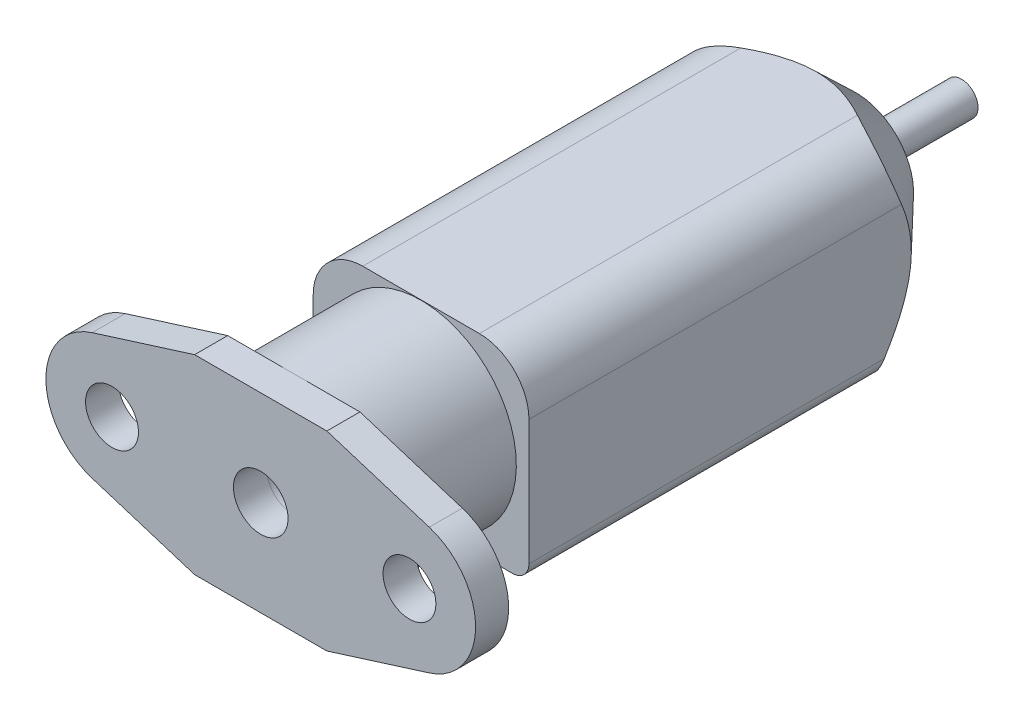
from build123d import *

# Parameters (mm, degrees)
CROQUIS1_R               = 1.598160281
CROQUIS1_R_2             = 1.600993429
CROQUIS1_R_3             = 1.650918845
SALIENTE_EXTRUIR7_DEPTH  = 2
CROQUIS2_R               = 5.764999893
CROQUIS2_R_2             = 1.651186543
SALIENTE_EXTRUIR8_DEPTH  = 7.7
SALIENTE_EXTRUIR9_DEPTH  = 26.3
CROQUIS6_R               = 0.999415005
SALIENTE_EXTRUIR10_DEPTH = 6.4


with BuildPart() as part:
    # Croquis1 → Saliente-Extruir7 (new body)
    with BuildSketch(Plane.XY):
        with BuildLine():
            Line((4.00000019, 5.763000809), (10.195969576, 3.8191034))
            ThreePointArc((10.195969576, 3.8191034), (12.999977706, 0.001566069), (10.197782, -3.817301838))
            Line((10.197782, -3.817301838), (4.00000019, -5.764999893))
            Line((4.00000019, -5.764999893), (-4.00000019, -5.764999893))
            Line((-4.00000019, -5.764999893), (-10.199065979, -3.817665654))
            ThreePointArc((-10.199065979, -3.817665654), (-13.000622723, -0.001109837), (-10.199143851, 3.815503142))
            Line((-10.199143851, 3.815503142), (-4.00000019, 5.763000809))
            Line((-4.00000019, 5.763000809), (4.00000019, 5.763000809))
        make_face()
        with Locations((8.997973452, 0.000616233)):
            Circle(CROQUIS1_R, mode=Mode.SUBTRACT)
        with Locations((-9.000145119, -0.001069025)):
            Circle(CROQUIS1_R_2, mode=Mode.SUBTRACT)
        Circle(CROQUIS1_R_3, mode=Mode.SUBTRACT)
    extrude(amount=-SALIENTE_EXTRUIR7_DEPTH)

    # Croquis2 → Saliente-Extruir8 (add)
    with BuildSketch(Plane(origin=(0, 0, -2), x_dir=(-1, 0, 0), z_dir=(0, 0, -1))):
        with Locations(Location((0, 0, 0), (0, 0, 91.508919394))):
            Circle(CROQUIS2_R)
        with Locations(Location((0, 0, 0), (0, 0, 180))):
            Circle(CROQUIS2_R_2, mode=Mode.SUBTRACT)
    extrude(amount=SALIENTE_EXTRUIR8_DEPTH)

    # Croquis3 → Saliente-Extruir9 (add)
    with BuildSketch(Plane(origin=(0, 0, -9.7), x_dir=(-1, 0, 0), z_dir=(0, 0, -1))):
        with BuildLine():
            Line((3.526868458, 5.783774708), (-3.526868458, 5.783774708))
            ThreePointArc((-3.526868458, 5.783774708), (-5.648188802, 4.905095052), (-6.526868458, 2.783774708))
            Line((-6.526868458, 2.783774708), (-6.526868458, -4.783774708))
            ThreePointArc((-6.526868458, -4.783774708), (-6.233975239, -5.490881489), (-5.526868458, -5.783774708))
            Line((-5.526868458, -5.783774708), (5.526868458, -5.783774708))
            ThreePointArc((5.526868458, -5.783774708), (6.233975239, -5.490881489), (6.526868458, -4.783774708))
            Line((6.526868458, -4.783774708), (6.526868458, 2.783774708))
            ThreePointArc((6.526868458, 2.783774708), (5.648188802, 4.905095052), (3.526868458, 5.783774708))
        make_face()
    extrude(amount=SALIENTE_EXTRUIR9_DEPTH)

    # Croquis5 → Cortar-Revolución1 (revolve, cut)
    with BuildSketch(Plane(origin=(0, 0, 0), x_dir=(1, 0, 0), z_dir=(0, 1, 0)), mode=Mode.PRIVATE) as cortar_revoluci_n1_sk:
        Polygon((-3.5, 36), (-8.472559386, 30.803521887), (-8.472559386, 36), align=None)
    revolve(cortar_revoluci_n1_sk.sketch.rotate(Axis((0, 0, -39.9199001), (0, 0, 1)), 203.098732746), axis=Axis((0, 0, -39.9199001), (0, 0, 1)), mode=Mode.SUBTRACT)

    # Croquis6 → Saliente-Extruir10 (add)
    with BuildSketch(Plane(origin=(0, 0, -36), x_dir=(-1, 0, 0), z_dir=(0, 0, -1))):
        Circle(CROQUIS6_R)
    extrude(amount=SALIENTE_EXTRUIR10_DEPTH)


solid = part.part
